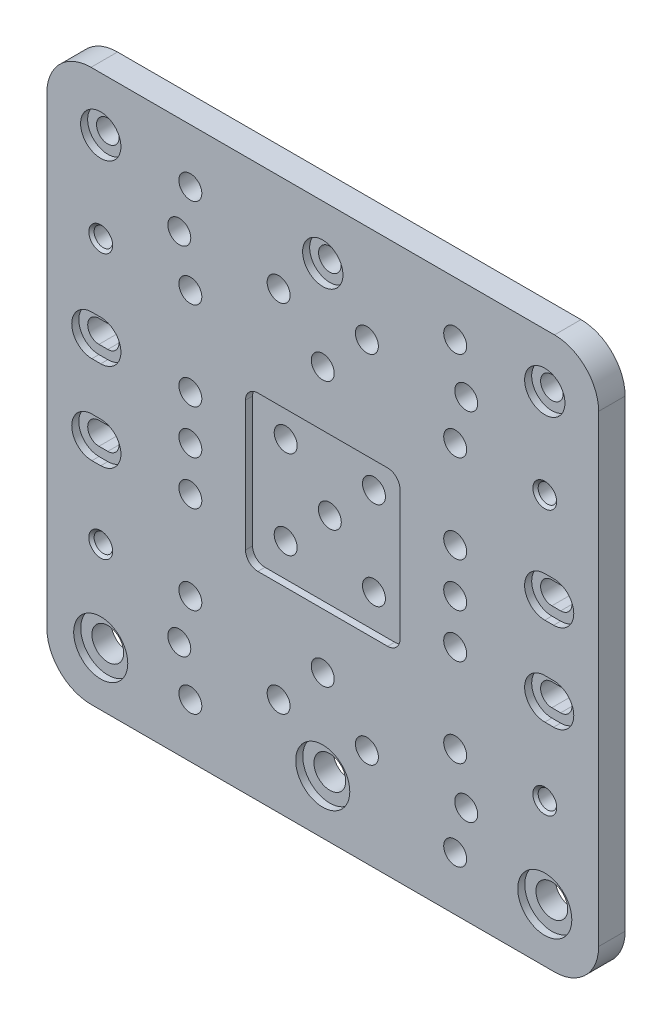
from build123d import *

# Parameters (mm, degrees)
SKETCH1_W             = 125
SKETCH1_H             = 125
BOSS_EXTRUDE1_DEPTH   = 6
M5_CLEARANCE_HOLE1_D  = 5.2
SKETCH4_R             = 2.55
SKETCH4_R_2           = 3.6
CUT_EXTRUDE1_DEPTH    = 7
SKETCH5_R             = 4.5675
SKETCH5_R_2           = 6.125
SKETCH5_W             = 35
SKETCH5_H             = 35
CUT_EXTRUDE2_DEPTH    = 1.6
FILLET1_R             = 10
FILLET2_R             = 2.8
M5X0_8_TAPPED_HOLE1_D = 4.2
CHAMFER1_SIZE         = 0.6


with BuildPart() as part:
    # Sketch1 → Boss-Extrude1 (new body)
    with BuildSketch(Plane.XY):
        Rectangle(SKETCH1_W, SKETCH1_H)
    extrude(amount=BOSS_EXTRUDE1_DEPTH)

    # M5 Clearance Hole1 (through all)
    with Locations(Plane.XY.offset(6)):
        with Locations((0, 0), (-10, 10), (-30, 30), (0, 30), (-30, 0), (-30, 10), (-30, -10), (0, -30), (-30, -30), (-10, -10), (10, -10), (30, -30), (30, -10), (30, 10), (30, 0), (30, 30), (10, 10), (-30, 50.3), (-32.5, 40.3), (-10, 40.3), (10, 40.3), (32.5, 40.3), (30, 50.3), (30, -50.3), (32.5, -40.3), (10, -40.3), (-10, -40.3), (-32.5, -40.3), (-30, -50.3)):
            Hole(M5_CLEARANCE_HOLE1_D / 2)

    # Sketch4 → Cut-Extrude1 (cut, through all)
    with BuildSketch(Plane.XY.offset(6)):
        with Locations((-50.3, 50.3)):
            Circle(SKETCH4_R)
        with Locations((0, 50.3)):
            Circle(SKETCH4_R)
        with Locations((-50.3, -50.3)):
            Circle(SKETCH4_R_2)
        with Locations((50.3, 50.3)):
            Circle(SKETCH4_R)
        with Locations((50.3, -50.3)):
            Circle(SKETCH4_R_2)
        with Locations((0, -50.3)):
            Circle(SKETCH4_R_2)
        with BuildLine():
            Line((-50.3, 7.45), (-52.3, 7.45))
            ThreePointArc((-52.3, 7.45), (-54.85, 10), (-52.3, 12.55))
            Line((-52.3, 12.55), (-50.3, 12.55))
            ThreePointArc((-50.3, 12.55), (-47.75, 10), (-50.3, 7.45))
        make_face()
        with BuildLine():
            Line((-50.3, -7.45), (-52.3, -7.45))
            ThreePointArc((-52.3, -7.45), (-54.85, -10), (-52.3, -12.55))
            Line((-52.3, -12.55), (-50.3, -12.55))
            ThreePointArc((-50.3, -12.55), (-47.75, -10), (-50.3, -7.45))
        make_face()
        with BuildLine():
            Line((50.3, 7.45), (52.3, 7.45))
            ThreePointArc((52.3, 7.45), (54.85, 10), (52.3, 12.55))
            Line((52.3, 12.55), (50.3, 12.55))
            ThreePointArc((50.3, 12.55), (47.75, 10), (50.3, 7.45))
        make_face()
        with BuildLine():
            Line((50.3, -7.45), (52.3, -7.45))
            ThreePointArc((52.3, -7.45), (54.85, -10), (52.3, -12.55))
            Line((52.3, -12.55), (50.3, -12.55))
            ThreePointArc((50.3, -12.55), (47.75, -10), (50.3, -7.45))
        make_face()
    extrude(amount=-CUT_EXTRUDE1_DEPTH, mode=Mode.SUBTRACT)

    # Sketch5 → Cut-Extrude2 (cut)
    with BuildSketch(Plane.XY.offset(6)):
        with Locations((-50.3, 50.3)):
            Circle(SKETCH5_R)
        with Locations((0, 50.3)):
            Circle(SKETCH5_R)
        with Locations((50.3, 50.3)):
            Circle(SKETCH5_R)
        with Locations((-50.3, -50.3)):
            Circle(SKETCH5_R_2)
        with Locations((0, -50.3)):
            Circle(SKETCH5_R_2)
        with Locations((50.3, -50.3)):
            Circle(SKETCH5_R_2)
        Rectangle(SKETCH5_W, SKETCH5_H)
        with BuildLine():
            Line((-50.3, 5.432), (-52.3, 5.432))
            ThreePointArc((-52.3, 5.432), (-56.868, 10), (-52.3, 14.568))
            Line((-52.3, 14.568), (-50.3, 14.568))
            ThreePointArc((-50.3, 14.568), (-45.732, 10), (-50.3, 5.432))
        make_face()
        with BuildLine():
            Line((-50.3, -14.568), (-52.3, -14.568))
            ThreePointArc((-52.3, -14.568), (-56.868, -10), (-52.3, -5.432))
            Line((-52.3, -5.432), (-50.3, -5.432))
            ThreePointArc((-50.3, -5.432), (-45.732, -10), (-50.3, -14.568))
        make_face()
        with BuildLine():
            Line((50.3, 14.568), (52.3, 14.568))
            ThreePointArc((52.3, 14.568), (56.868, 10), (52.3, 5.432))
            Line((52.3, 5.432), (50.3, 5.432))
            ThreePointArc((50.3, 5.432), (45.732, 10), (50.3, 14.568))
        make_face()
        with BuildLine():
            Line((50.3, -5.432), (52.3, -5.432))
            ThreePointArc((52.3, -5.432), (56.868, -10), (52.3, -14.568))
            Line((52.3, -14.568), (50.3, -14.568))
            ThreePointArc((50.3, -14.568), (45.732, -10), (50.3, -5.432))
        make_face()
    extrude(amount=-CUT_EXTRUDE2_DEPTH, mode=Mode.SUBTRACT)

    # Fillet1
    fillet1_edges = [part.edges().sort_by_distance(p)[0] for p in [
        (-62.5, 62.5, 3),
        (62.5, 62.5, 3),
        (62.5, -62.5, 3),
        (-62.5, -62.5, 3),
    ]]
    fillet(fillet1_edges, radius=FILLET1_R)

    # Fillet2
    fillet2_edges = [part.edges().sort_by_distance(p)[0] for p in [
        (-17.5, -17.5, 5.2),
        (-17.5, 17.5, 5.2),
        (17.5, 17.5, 5.2),
        (17.5, -17.5, 5.2),
    ]]
    fillet(fillet2_edges, radius=FILLET2_R)

    # M5x0.8 Tapped Hole1 (through all)
    with Locations(Plane.XY.offset(6)):
        with Locations((-50.3, 30), (50.3, 30), (50.3, -30), (-50.3, -30)):
            Hole(M5X0_8_TAPPED_HOLE1_D / 2)

    # Chamfer1
    chamfer1_edges = [part.edges().sort_by_distance(p)[0] for p in [
        (-48.2, -30, 6),
        (52.4, -30, 6),
        (52.4, 30, 6),
        (-48.2, 30, 6),
    ]]
    chamfer(chamfer1_edges, length=CHAMFER1_SIZE)


solid = part.part
